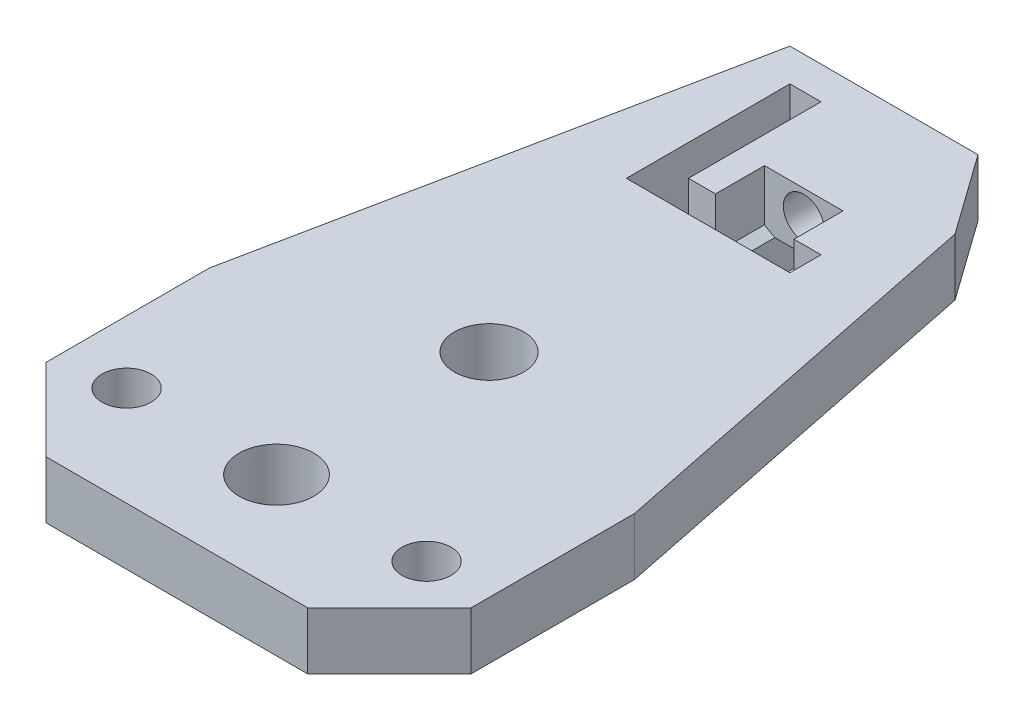
from build123d import *

# Parameters (mm, degrees)
SKETCH1_R           = 4.25
SKETCH1_R_2         = 4.575
SKETCH1_R_3         = 3
BOSS_EXTRUDE1_DEPTH = 7
BOSS_EXTRUDE2_DEPTH = 7
SKETCH5_W           = 15
SKETCH5_H           = 17.175
BOSS_EXTRUDE3_DEPTH = 15
SKETCH6_R           = 4.2
CUT_EXTRUDE3_DEPTH  = 34.505
CUT_EXTRUDE4_DEPTH  = 8
CUT_EXTRUDE5_DEPTH  = 2
CUT_EXTRUDE6_DEPTH  = 34.5050001
BOSS_EXTRUDE6_DEPTH = 7
CUT_EXTRUDE1_DEPTH  = 6
SKETCH3_R           = 2.5
CUT_EXTRUDE2_DEPTH  = 15.2100001


with BuildPart() as part:
    # Sketch1 → Boss-Extrude1 (new body)
    with BuildSketch(Plane(origin=(0, 0, 0), x_dir=(1, 0, 0), z_dir=(0, 1, 0))):
        Polygon((0, 28.01), (0, -31), (-12, -31), (-12, -61), (40.01, -61), (40.01, -31), (28.01, -31), (28.01, 28.01), align=None)
        Polygon((4, 4), (4, 24.01), (7.8, 24.01), (7.8, 7.8), (24.01, 7.8), (24.01, 4), align=None, mode=Mode.SUBTRACT)
        with Locations((14, -22.8)):
            Circle(SKETCH1_R, mode=Mode.SUBTRACT)
        with Locations((14, -48.8)):
            Circle(SKETCH1_R_2, mode=Mode.SUBTRACT)
        with Locations((-4.3415, -48.8)):
            Circle(SKETCH1_R_3, mode=Mode.SUBTRACT)
        with Locations((32.3515, -48.8)):
            Circle(SKETCH1_R_3, mode=Mode.SUBTRACT)
    extrude(amount=BOSS_EXTRUDE1_DEPTH)

    # Sketch4 → Boss-Extrude2 (add)
    with BuildSketch(Plane.XZ):
        Polygon((40.01, 31), (28.01, -28.01), (28.01, 31), align=None)
        Polygon((0, 31), (-12, 31), (0, -28.01), align=None)
    extrude(amount=-BOSS_EXTRUDE2_DEPTH)

    # Sketch5 → Boss-Extrude3 (add)
    with BuildSketch(Plane(origin=(0, 0, 0), x_dir=(-1, 0, 0), z_dir=(0, -1, 0))):
        with Locations((-14.005, -35.6375)):
            Rectangle(SKETCH5_W, SKETCH5_H)
    extrude(amount=BOSS_EXTRUDE3_DEPTH)

    # Sketch6 → Cut-Extrude3 (cut, through all)
    with BuildSketch(Plane.ZY.offset(-6.505)):
        with Locations((35.6375, -8.2)):
            Circle(SKETCH6_R)
    extrude(amount=-CUT_EXTRUDE3_DEPTH, mode=Mode.SUBTRACT)

    # Sketch7 → Cut-Extrude4 (cut, through all)
    with BuildSketch(Plane.XZ):
        Polygon((-2, 61), (-12, 51), (-12, 61), align=None)
        Polygon((40.01, 51), (30.01, 61), (40.01, 61), align=None)
        Polygon((23.01, -28.01), (30.002767175, -18.210567415), (28.01, -28.01), align=None)
    extrude(amount=-CUT_EXTRUDE4_DEPTH, mode=Mode.SUBTRACT)

    # Sketch8 → Cut-Extrude5 (cut)
    with BuildSketch(Plane(origin=(0, 0, 0), x_dir=(-1, 0, 0), z_dir=(0, -1, 0))):
        with BuildLine():
            Line((4.82438251, -18.952595637), (4.282715843, -18.382082817))
            add(Edge.make_bspline(
                [(4.282715843, -18.382082817), (4.33287284, -18.332874363), (4.432437495, -18.235192625), (4.571920583, -18.081852997), (4.699076528, -17.921796438), (4.816137392, -17.757270248), (4.922118922, -17.586278285), (5.01879791, -17.410925133), (5.101505936, -17.228622872), (5.200600149, -16.980815028), (5.295507972, -16.658167031), (5.363850028, -16.257618519), (5.389834317, -15.843501349), (5.369817604, -15.565245284), (5.35963892, -15.423749483)],
                knots=[0, 0, 0, 0, 0.000210772, 0.000418396, 0.000621371, 0.000823688, 0.001023797, 0.001224598, 0.001423942, 0.001623922, 0.002025015, 0.00242996, 0.00284092, 0.00326611, 0.00326611, 0.00326611, 0.00326611], degree=3))
            add(Edge.make_bspline(
                [(5.35963892, -15.423749483), (5.350507889, -15.346145049), (5.332339815, -15.191734987), (5.287213952, -14.964112589), (5.226592795, -14.742712857), (5.157802642, -14.525277968), (5.069861221, -14.315728159), (4.971050763, -14.111140047), (4.856035736, -13.913944388), (4.730618033, -13.722324701), (4.592796507, -13.539970689), (4.445758333, -13.368517289), (4.289414969, -13.209610989), (4.126774309, -13.061559821), (3.953595851, -12.928049071), (3.772874275, -12.806165101), (3.582594377, -12.696696645), (3.384784335, -12.600012416), (3.181205017, -12.513429796), (2.970851251, -12.446294773), (2.757415531, -12.388340369), (2.538451786, -12.349807427), (2.316036881, -12.321095954), (2.088402986, -12.311584286), (1.85657933, -12.311264407), (1.700926578, -12.325318452), (1.622459433, -12.33240333)],
                knots=[0, 0, 0, 0, 0.000234358, 0.000466304, 0.000695269, 0.000922816, 0.001149889, 0.001376373, 0.001603971, 0.001834211, 0.002063058, 0.002289201, 0.002511316, 0.002731446, 0.002948462, 0.003166699, 0.003384954, 0.003606415, 0.003826953, 0.004047909, 0.004268307, 0.004489907, 0.004714324, 0.004940563, 0.005172941, 0.005409176, 0.005409176, 0.005409176, 0.005409176], degree=3))
            add(Edge.make_bspline(
                [(1.622459433, -12.33240333), (1.505097937, -12.347291585), (1.274299094, -12.376570287), (0.939241051, -12.457754728), (0.622377858, -12.568110532), (0.323678403, -12.709065571), (0.041731569, -12.877105008), (-0.220513567, -13.077230537), (-0.463451643, -13.307210827), (-0.688567371, -13.561504181), (-0.886917396, -13.838520449), (-1.05731935, -14.130375558), (-1.193946155, -14.436228501), (-1.298224728, -14.755935623), (-1.372848018, -15.087995537), (-1.4113042, -15.433871562), (-1.422635295, -15.792212989), (-1.403373763, -16.034404952), (-1.393566208, -16.157723842)],
                knots=[0, 0, 0, 0, 0.000354688, 0.000697517, 0.001032027, 0.001359649, 0.001686705, 0.002014918, 0.002347098, 0.002688865, 0.003032207, 0.003367545, 0.003701113, 0.004035081, 0.004374904, 0.004720185, 0.005077686, 0.005448558, 0.005448558, 0.005448558, 0.005448558], degree=3))
            add(Edge.make_bspline(
                [(-1.393566208, -16.157723842), (-1.376419223, -16.29292117), (-1.342707378, -16.558725993), (-1.238482387, -16.942990687), (-1.100029169, -17.306940037), (-0.919786483, -17.649368778), (-0.703089714, -17.971575401), (-0.445379036, -18.270715409), (-0.151188174, -18.551161526), (0.070321299, -18.71403375), (0.183356868, -18.797146919)],
                knots=[0, 0, 0, 0, 0.000408412, 0.000802958, 0.001191047, 0.001574542, 0.001961239, 0.002353383, 0.002756955, 0.003177499, 0.003177499, 0.003177499, 0.003177499], degree=3))
            Line((0.183356868, -18.797146919), (-0.223694414, -19.46541615))
            add(Edge.make_bspline(
                [(-0.223694414, -19.46541615), (-0.289856697, -19.421744788), (-0.421920826, -19.334573969), (-0.61124881, -19.192302165), (-0.789119358, -19.03764426), (-0.958208109, -18.873421951), (-1.118302663, -18.699503779), (-1.267394473, -18.514282481), (-1.407608777, -18.319908616), (-1.536551496, -18.115180205), (-1.65625625, -17.901883661), (-1.760748496, -17.678869245), (-1.856455603, -17.449457092), (-1.937514134, -17.21143408), (-2.00847314, -16.966685861), (-2.065741267, -16.713448159), (-2.113026061, -16.453155227), (-2.133330301, -16.275919326), (-2.143566208, -16.186569996)],
                knots=[0, 0, 0, 0, 0.000237796, 0.000474656, 0.00070984, 0.000944434, 0.001181489, 0.001418506, 0.001657336, 0.001900086, 0.002143997, 0.002390589, 0.002638495, 0.002889361, 0.003144491, 0.003402624, 0.003667944, 0.00393768, 0.00393768, 0.00393768, 0.00393768], degree=3))
            add(Edge.make_bspline(
                [(-2.143566208, -16.186569996), (-2.151484407, -16.101159277), (-2.167101443, -15.932704005), (-2.173396993, -15.682347897), (-2.173529458, -15.437946689), (-2.157800785, -15.199537288), (-2.134856164, -14.966149844), (-2.098177435, -14.738625208), (-2.047434089, -14.517089349), (-1.988806727, -14.300683294), (-1.918723551, -14.089926851), (-1.833938922, -13.886536903), (-1.742226547, -13.686875476), (-1.635204372, -13.494521171), (-1.518684075, -13.306880412), (-1.38969504, -13.124957852), (-1.249212207, -12.949142977), (-1.14789509, -12.837235048), (-1.097091849, -12.781121278)],
                knots=[0, 0, 0, 0, 0.000257255, 0.000507384, 0.000750979, 0.000990196, 0.001223808, 0.001454338, 0.001681003, 0.001905327, 0.002126789, 0.002346714, 0.002566096, 0.002785571, 0.003006574, 0.003228452, 0.003454203, 0.003681248, 0.003681248, 0.003681248, 0.003681248], degree=3))
            add(Edge.make_bspline(
                [(-1.097091849, -12.781121278), (-1.007383858, -12.691197511), (-0.829061214, -12.512445945), (-0.53402084, -12.277271258), (-0.221658643, -12.071169666), (0.108283376, -11.893580441), (0.457318853, -11.747651196), (0.824965729, -11.632570406), (1.210307715, -11.544785172), (1.475190846, -11.5112725), (1.60963892, -11.494262304)],
                knots=[0, 0, 0, 0, 0.000380811, 0.00075698, 0.001129451, 0.001502284, 0.001879381, 0.002262551, 0.002656782, 0.003063142, 0.003063142, 0.003063142, 0.003063142], degree=3))
            add(Edge.make_bspline(
                [(1.60963892, -11.494262304), (1.751643235, -11.483393164), (2.03073324, -11.46203136), (2.44538457, -11.47940476), (2.846291285, -11.535447574), (3.234850831, -11.630018772), (3.609945246, -11.765187019), (3.971130641, -11.941468078), (4.318116629, -12.157336797), (4.648130873, -12.410120704), (4.955489466, -12.691948505), (5.229502887, -13.002016081), (5.469408797, -13.333714872), (5.676367364, -13.687662479), (5.845002227, -14.066899855), (5.976701101, -14.468892896), (6.078768404, -14.89269308), (6.115140001, -15.185017802), (6.133677381, -15.334005894)],
                knots=[0, 0, 0, 0, 0.000426959, 0.00083913, 0.001242091, 0.001639714, 0.002036636, 0.002435855, 0.002843209, 0.003260531, 0.003681286, 0.004092256, 0.004499688, 0.004907584, 0.005320069, 0.005742214, 0.006175241, 0.006625342, 0.006625342, 0.006625342, 0.006625342], degree=3))
            add(Edge.make_bspline(
                [(6.133677381, -15.334005894), (6.141612892, -15.425289178), (6.157278206, -15.605489453), (6.163333834, -15.874116165), (6.154971831, -16.136696164), (6.135037737, -16.394758096), (6.098014661, -16.647339899), (6.04594515, -16.894765129), (5.983118444, -17.137354441), (5.901892189, -17.372761168), (5.809484865, -17.60125649), (5.705087207, -17.821990264), (5.588075413, -18.033206625), (5.459749535, -18.235575578), (5.319624301, -18.428870339), (5.167475419, -18.613350154), (5.00201913, -18.788414259), (4.883779608, -18.897697624), (4.82438251, -18.952595637)],
                knots=[0, 0, 0, 0, 0.000274829, 0.000542534, 0.000805477, 0.001062732, 0.001318606, 0.001570672, 0.001821006, 0.002069837, 0.002317136, 0.002560146, 0.002801878, 0.003041063, 0.003278594, 0.00351764, 0.003757971, 0.004000567, 0.004000567, 0.004000567, 0.004000567], degree=3))
        make_face()
        with BuildLine():
            Line((5.740498881, -27.931622685), (5.198832214, -27.361109864))
            add(Edge.make_bspline(
                [(5.198832214, -27.361109864), (5.248989212, -27.31190141), (5.348553866, -27.214219672), (5.488036954, -27.060880045), (5.615192899, -26.900823485), (5.732253763, -26.736297296), (5.838235294, -26.565305332), (5.934914282, -26.389952181), (6.017622307, -26.207649919), (6.11671652, -25.959842075), (6.211624344, -25.637194079), (6.2799664, -25.236645566), (6.305950688, -24.822528396), (6.285933976, -24.544272331), (6.275755291, -24.402776531)],
                knots=[0, 0, 0, 0, 0.000210772, 0.000418396, 0.000621371, 0.000823688, 0.001023797, 0.001224598, 0.001423942, 0.001623922, 0.002025015, 0.00242996, 0.00284092, 0.00326611, 0.00326611, 0.00326611, 0.00326611], degree=3))
            add(Edge.make_bspline(
                [(6.275755291, -24.402776531), (6.26662426, -24.325172096), (6.248456187, -24.170762034), (6.203330324, -23.943139636), (6.142709166, -23.721739904), (6.073919013, -23.504305015), (5.985977593, -23.294755207), (5.887167134, -23.090167094), (5.772152107, -22.892971436), (5.646734405, -22.701351749), (5.508912878, -22.518997736), (5.361874704, -22.347544337), (5.20553134, -22.188638036), (5.04289068, -22.040586868), (4.869712223, -21.907076119), (4.688990646, -21.785192148), (4.498710748, -21.675723692), (4.300900706, -21.579039463), (4.097321389, -21.492456844), (3.886967622, -21.42532182), (3.673531902, -21.367367416), (3.454568157, -21.328834475), (3.232153252, -21.300123001), (3.004519357, -21.290611333), (2.772695702, -21.290291455), (2.61704295, -21.304345499), (2.538575804, -21.311430377)],
                knots=[0, 0, 0, 0, 0.000234358, 0.000466304, 0.000695269, 0.000922816, 0.001149889, 0.001376373, 0.001603971, 0.001834211, 0.002063058, 0.002289201, 0.002511316, 0.002731446, 0.002948462, 0.003166699, 0.003384954, 0.003606415, 0.003826953, 0.004047909, 0.004268307, 0.004489907, 0.004714324, 0.004940563, 0.005172941, 0.005409176, 0.005409176, 0.005409176, 0.005409176], degree=3))
            add(Edge.make_bspline(
                [(2.538575804, -21.311430377), (2.421214309, -21.326318633), (2.190415465, -21.355597334), (1.855357422, -21.436781775), (1.53849423, -21.54713758), (1.239794775, -21.688092618), (0.95784794, -21.856132055), (0.695602804, -22.056257584), (0.452664729, -22.286237874), (0.227549001, -22.540531229), (0.029198976, -22.817547497), (-0.141202979, -23.109402605), (-0.277829784, -23.415255548), (-0.382108357, -23.73496267), (-0.456731647, -24.067022584), (-0.495187829, -24.412898609), (-0.506518924, -24.771240037), (-0.487257391, -25.013432), (-0.477449837, -25.13675089)],
                knots=[0, 0, 0, 0, 0.000354688, 0.000697517, 0.001032027, 0.001359649, 0.001686705, 0.002014918, 0.002347098, 0.002688865, 0.003032207, 0.003367545, 0.003701113, 0.004035081, 0.004374904, 0.004720185, 0.005077686, 0.005448558, 0.005448558, 0.005448558, 0.005448558], degree=3))
            add(Edge.make_bspline(
                [(-0.477449837, -25.13675089), (-0.460302852, -25.271948217), (-0.426591006, -25.53775304), (-0.322366016, -25.922017735), (-0.183912798, -26.285967084), (-0.003670111, -26.628395826), (0.213026657, -26.950602448), (0.470737335, -27.249742457), (0.764928197, -27.530188574), (0.986437671, -27.693060797), (1.09947324, -27.776173967)],
                knots=[0, 0, 0, 0, 0.000408412, 0.000802958, 0.001191047, 0.001574542, 0.001961239, 0.002353383, 0.002756955, 0.003177499, 0.003177499, 0.003177499, 0.003177499], degree=3))
            Line((1.09947324, -27.776173967), (0.692421958, -28.444443198))
            add(Edge.make_bspline(
                [(0.692421958, -28.444443198), (0.626259674, -28.400771835), (0.494195546, -28.313601016), (0.304867561, -28.171329213), (0.126997013, -28.016671308), (-0.042091738, -27.852448998), (-0.202186292, -27.678530827), (-0.351278101, -27.493309528), (-0.491492406, -27.298935664), (-0.620435125, -27.094207253), (-0.740139879, -26.880910709), (-0.844632125, -26.657896292), (-0.940339232, -26.428484139), (-1.021397763, -26.190461127), (-1.092356768, -25.945712908), (-1.149624896, -25.692475207), (-1.19690969, -25.432182275), (-1.21721393, -25.254946373), (-1.227449837, -25.165597044)],
                knots=[0, 0, 0, 0, 0.000237796, 0.000474656, 0.00070984, 0.000944434, 0.001181489, 0.001418506, 0.001657336, 0.001900086, 0.002143997, 0.002390589, 0.002638495, 0.002889361, 0.003144491, 0.003402624, 0.003667944, 0.00393768, 0.00393768, 0.00393768, 0.00393768], degree=3))
            add(Edge.make_bspline(
                [(-1.227449837, -25.165597044), (-1.235368035, -25.080186325), (-1.250985071, -24.911731053), (-1.257280622, -24.661374945), (-1.257413087, -24.416973737), (-1.241684413, -24.178564335), (-1.218739793, -23.945176891), (-1.182061064, -23.717652256), (-1.131317718, -23.496116397), (-1.072690355, -23.279710341), (-1.002607179, -23.068953898), (-0.91782255, -22.86556395), (-0.826110176, -22.665902524), (-0.719088001, -22.473548219), (-0.602567704, -22.285907459), (-0.473578669, -22.1039849), (-0.333095836, -21.928170024), (-0.231778719, -21.816262096), (-0.180975478, -21.760148326)],
                knots=[0, 0, 0, 0, 0.000257255, 0.000507384, 0.000750979, 0.000990196, 0.001223808, 0.001454338, 0.001681003, 0.001905327, 0.002126789, 0.002346714, 0.002566096, 0.002785571, 0.003006574, 0.003228452, 0.003454203, 0.003681248, 0.003681248, 0.003681248, 0.003681248], degree=3))
            add(Edge.make_bspline(
                [(-0.180975478, -21.760148326), (-0.091267487, -21.670224558), (0.087055157, -21.491472992), (0.382095532, -21.256298305), (0.694457728, -21.050196713), (1.024399747, -20.872607488), (1.373435224, -20.726678244), (1.741082101, -20.611597453), (2.126424087, -20.523812219), (2.391307218, -20.490299548), (2.525755291, -20.473289351)],
                knots=[0, 0, 0, 0, 0.000380811, 0.00075698, 0.001129451, 0.001502284, 0.001879381, 0.002262551, 0.002656782, 0.003063142, 0.003063142, 0.003063142, 0.003063142], degree=3))
            add(Edge.make_bspline(
                [(2.525755291, -20.473289351), (2.667759606, -20.462420211), (2.946849612, -20.441058407), (3.361500941, -20.458431808), (3.762407656, -20.514474621), (4.150967202, -20.60904582), (4.526061618, -20.744214067), (4.887247012, -20.920495126), (5.234233, -21.136363844), (5.564247244, -21.389147751), (5.871605837, -21.670975552), (6.145619259, -21.981043128), (6.385525168, -22.312741919), (6.592483735, -22.666689526), (6.761118598, -23.045926902), (6.892817472, -23.447919943), (6.994884776, -23.871720128), (7.031256372, -24.16404485), (7.049793753, -24.313032941)],
                knots=[0, 0, 0, 0, 0.000426959, 0.00083913, 0.001242091, 0.001639714, 0.002036636, 0.002435855, 0.002843209, 0.003260531, 0.003681286, 0.004092256, 0.004499688, 0.004907584, 0.005320069, 0.005742214, 0.006175241, 0.006625342, 0.006625342, 0.006625342, 0.006625342], degree=3))
            add(Edge.make_bspline(
                [(7.049793753, -24.313032941), (7.057729264, -24.404316225), (7.073394577, -24.5845165), (7.079450206, -24.853143213), (7.071088203, -25.115723211), (7.051154108, -25.373785144), (7.014131032, -25.626366946), (6.962061521, -25.873792177), (6.899234816, -26.116381488), (6.818008561, -26.351788215), (6.725601236, -26.580283537), (6.621203578, -26.801017311), (6.504191785, -27.012233673), (6.375865906, -27.214602625), (6.235740673, -27.407897386), (6.083591791, -27.592377201), (5.918135501, -27.767441307), (5.799895979, -27.876724672), (5.740498881, -27.931622685)],
                knots=[0, 0, 0, 0, 0.000274829, 0.000542534, 0.000805477, 0.001062732, 0.001318606, 0.001570672, 0.001821006, 0.002069837, 0.002317136, 0.002560146, 0.002801878, 0.003041063, 0.003278594, 0.00351764, 0.003757971, 0.004000567, 0.004000567, 0.004000567, 0.004000567], degree=3))
        make_face()
    extrude(amount=-CUT_EXTRUDE5_DEPTH, mode=Mode.SUBTRACT)

    # Sketch9 → Cut-Extrude6 (cut, through all)
    with BuildSketch(Plane(origin=(21.505, 0, 0), x_dir=(0, 0, -1), z_dir=(1, 0, 0))):
        Polygon((-27.05, -15), (-32.05, -15), (-27.05, -10), align=None)
        Polygon((-44.225, -10), (-44.225, -15), (-39.225, -15), align=None)
    extrude(amount=-CUT_EXTRUDE6_DEPTH, mode=Mode.SUBTRACT)

    # Sketch12 → Boss-Extrude6 (add)
    with BuildSketch(Plane.XZ):
        Polygon((9.8, -26.01), (9.8, -9.8), (26.01, -9.8), (26.01, -2), (2, -2), (2, -26.01), align=None)
        Polygon((7.8, -24.01), (4, -24.01), (4, -4), (24.01, -4), (24.01, -7.8), (7.8, -7.8), align=None, mode=Mode.SUBTRACT)
    extrude(amount=BOSS_EXTRUDE6_DEPTH)

    # Sketch2 → Cut-Extrude1 (cut)
    with BuildSketch(Plane.XY.offset(-7.8)):
        Polygon((19.442822174, 7), (15.905, 9.042562584), (12.367177826, 7), (11.105, 6.271281292), (11.105, 0.728718708), (15.905, -2.042562584), (20.705, 0.728718708), (20.705, 6.271281292), align=None)
        Polygon((11.105, 6.271281292), (12.367177826, 7), (11.105, 7), align=None)
        Polygon((20.705, 7), (19.442822174, 7), (20.705, 6.271281292), align=None)
    extrude(amount=-CUT_EXTRUDE1_DEPTH, mode=Mode.SUBTRACT)

    # Sketch3 → Cut-Extrude2 (cut, through all)
    with BuildSketch(Plane.XY.offset(-13.8)):
        with Locations((15.905, 3.864359354)):
            Circle(SKETCH3_R)
    extrude(amount=-CUT_EXTRUDE2_DEPTH, mode=Mode.SUBTRACT)


solid = part.part
